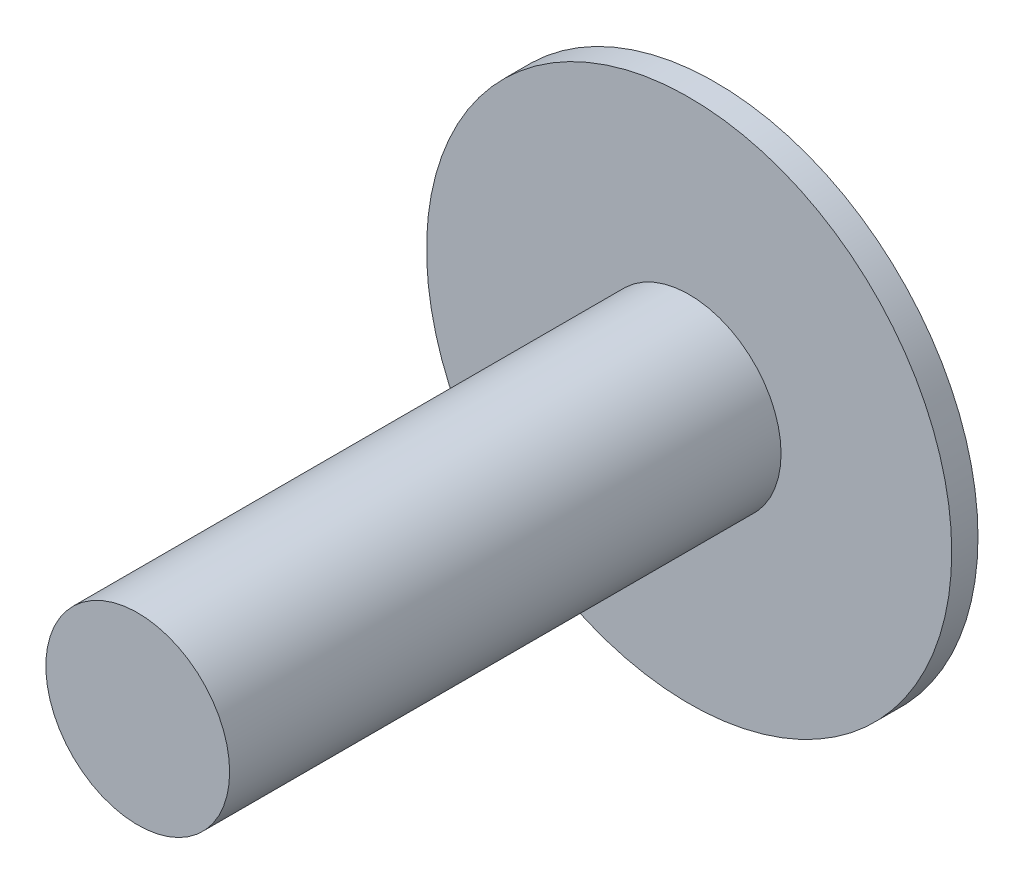
from build123d import *

# Parameters (mm, degrees)
CROQUIS1_R              = 10
SALIENTE_EXTRUIR1_DEPTH = 1
CROQUIS2_R              = 3.5
SALIENTE_EXTRUIR2_DEPTH = 21


with BuildPart() as part:
    # Croquis1 → Saliente-Extruir1 (new body)
    with BuildSketch(Plane.XY):
        Circle(CROQUIS1_R)
    extrude(amount=SALIENTE_EXTRUIR1_DEPTH)

    # Croquis2 → Saliente-Extruir2 (add)
    with BuildSketch(Plane.XY.offset(1)):
        Circle(CROQUIS2_R)
    extrude(amount=SALIENTE_EXTRUIR2_DEPTH)


solid = part.part
